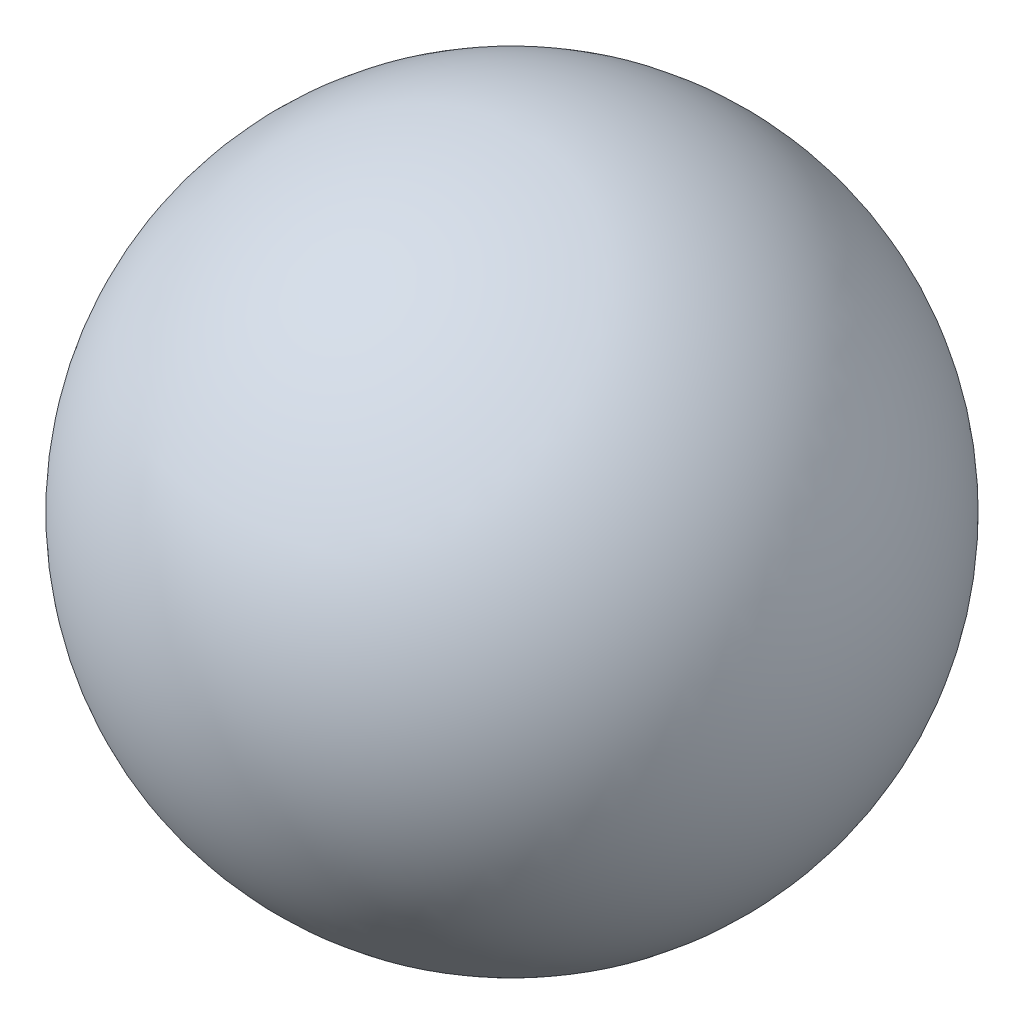
from build123d import *


with BuildPart() as part:
    # Sketch2 → Revolve1 (revolve)
    with BuildSketch(Plane.XY):
        with BuildLine():
            Line((0, 19.05), (0, 18.5674))
            ThreePointArc((0, 18.5674), (18.5674, 0), (0, -18.5674))
            Line((0, -18.5674), (0, -19.05))
            ThreePointArc((0, -19.05), (19.05, 0), (0, 19.05))
        make_face()
    revolve(axis=Axis((0, -158.486323131, 0), (0, 1, 0)))


solid = part.part
